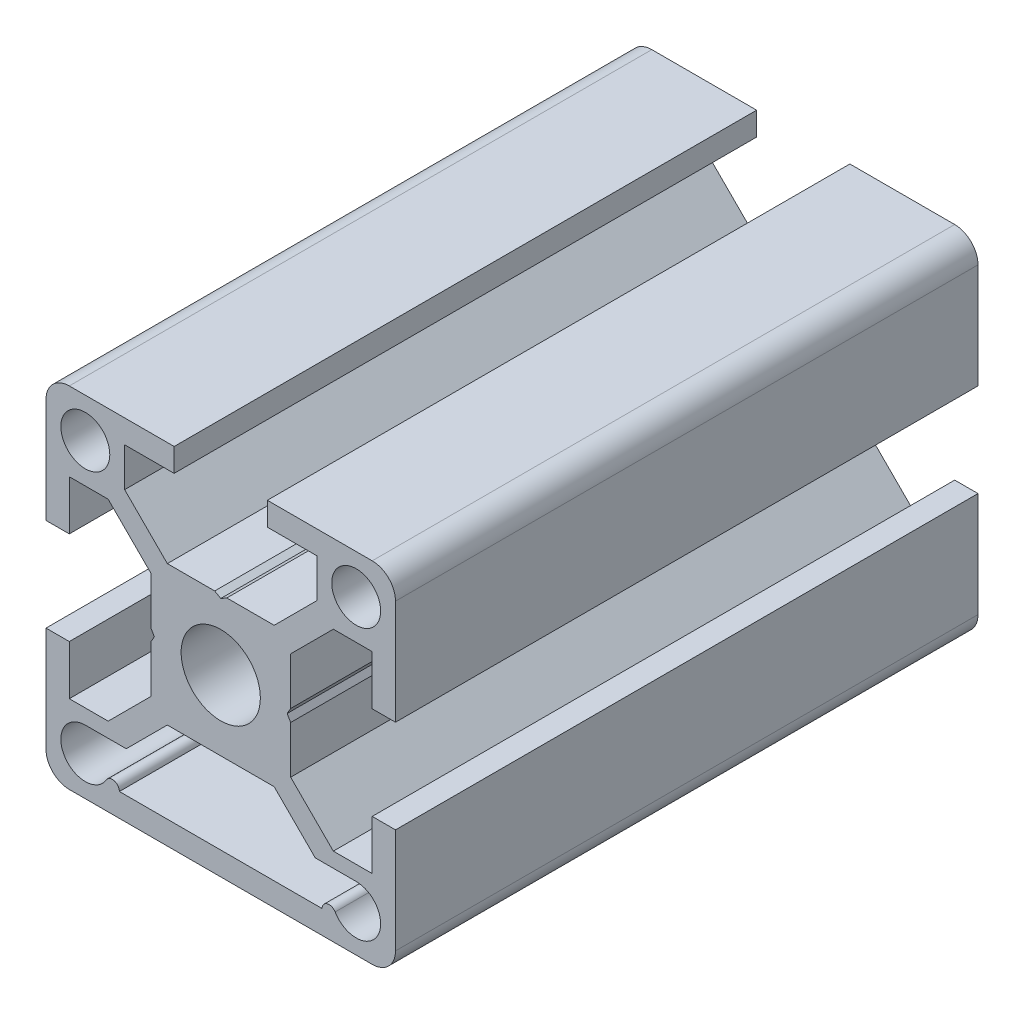
from build123d import *

# Parameters (mm, degrees)
SKETCH1_R      = 3.4
SKETCH1_R_2    = 2.1
EXTRUDE1_DEPTH = 50


with BuildPart() as part:
    # Sketch1 → Extrude1 (new body)
    with BuildSketch(Plane(origin=(0, 0, -50), x_dir=(-1, 0, 0), z_dir=(0, 0, -1))):
        with BuildLine():
            Line((13, 4), (15, 4))
            Line((15, 4), (15, 13))
            ThreePointArc((15, 13), (14.414213562, 14.414213562), (13, 15))
            Line((13, 15), (4, 15))
            Line((4, 15), (4, 13))
            Line((4, 13), (8.25, 13))
            Line((8.25, 13), (8.25, 9.664213562))
            Line((8.25, 9.664213562), (4.585786438, 6))
            Line((4.585786438, 6), (0.519615242, 6))
            Line((0.519615242, 6), (0, 5.7))
            Line((0, 5.7), (-0.519615242, 6))
            Line((-0.519615242, 6), (-4.585786438, 6))
            Line((-4.585786438, 6), (-8.25, 9.664213562))
            Line((-8.25, 9.664213562), (-8.25, 13))
            Line((-8.25, 13), (-4, 13))
            Line((-4, 13), (-4, 15))
            Line((-4, 15), (-13, 15))
            ThreePointArc((-13, 15), (-14.414213562, 14.414213562), (-15, 13))
            Line((-15, 13), (-15, 4))
            Line((-15, 4), (-13, 4))
            Line((-13, 4), (-13, 8.25))
            Line((-13, 8.25), (-9.664213562, 8.25))
            Line((-9.664213562, 8.25), (-6, 4.585786438))
            Line((-6, 4.585786438), (-6, 0.519615242))
            Line((-6, 0.519615242), (-5.7, 0))
            Line((-5.7, 0), (-6, -0.519615242))
            Line((-6, -0.519615242), (-6, -4.585786438))
            Line((-6, -4.585786438), (-9.664213562, -8.25))
            Line((-9.664213562, -8.25), (-13, -8.25))
            Line((-13, -8.25), (-13, -4))
            Line((-13, -4), (-15, -4))
            Line((-15, -4), (-15, -13))
            ThreePointArc((-15, -13), (-14.414213562, -14.414213562), (-13, -15))
            Line((-13, -15), (13, -15))
            ThreePointArc((13, -15), (14.414213562, -14.414213562), (15, -13))
            Line((15, -13), (15, -4))
            Line((15, -4), (13, -4))
            Line((13, -4), (13, -8.25))
            Line((13, -8.25), (9.664213562, -8.25))
            Line((9.664213562, -8.25), (6, -4.585786438))
            Line((6, -4.585786438), (6, -0.519615242))
            Line((6, -0.519615242), (5.7, 0))
            Line((5.7, 0), (6, 0.519615242))
            Line((6, 0.519615242), (6, 4.585786438))
            Line((6, 4.585786438), (9.664213562, 8.25))
            Line((9.664213562, 8.25), (13, 8.25))
            Line((13, 8.25), (13, 4))
        make_face()
        Circle(SKETCH1_R, mode=Mode.SUBTRACT)
        with Locations((-11.625, 11.625)):
            Circle(SKETCH1_R_2, mode=Mode.SUBTRACT)
        with Locations((11.625, 11.625)):
            Circle(SKETCH1_R_2, mode=Mode.SUBTRACT)
        with BuildLine():
            Line((8.701344475, -13), (-8.701344475, -13))
            ThreePointArc((-8.701344475, -13), (-9.142947405, -12.42128559), (-9.817712369, -12.694444444))
            ThreePointArc((-9.817712369, -12.694444444), (-13.44925784, -12.665232346), (-11.625, -9.525))
            Line((-11.625, -9.525), (-8.110786438, -9.525))
            Line((-8.110786438, -9.525), (-4.585786438, -6))
            Line((-4.585786438, -6), (4.585786438, -6))
            Line((4.585786438, -6), (8.110786438, -9.525))
            Line((8.110786438, -9.525), (11.625, -9.525))
            ThreePointArc((11.625, -9.525), (13.44925784, -12.665232346), (9.817712369, -12.694444444))
            ThreePointArc((9.817712369, -12.694444444), (9.142947405, -12.42128559), (8.701344475, -13))
        make_face(mode=Mode.SUBTRACT)
    extrude(amount=-EXTRUDE1_DEPTH)


solid = part.part
